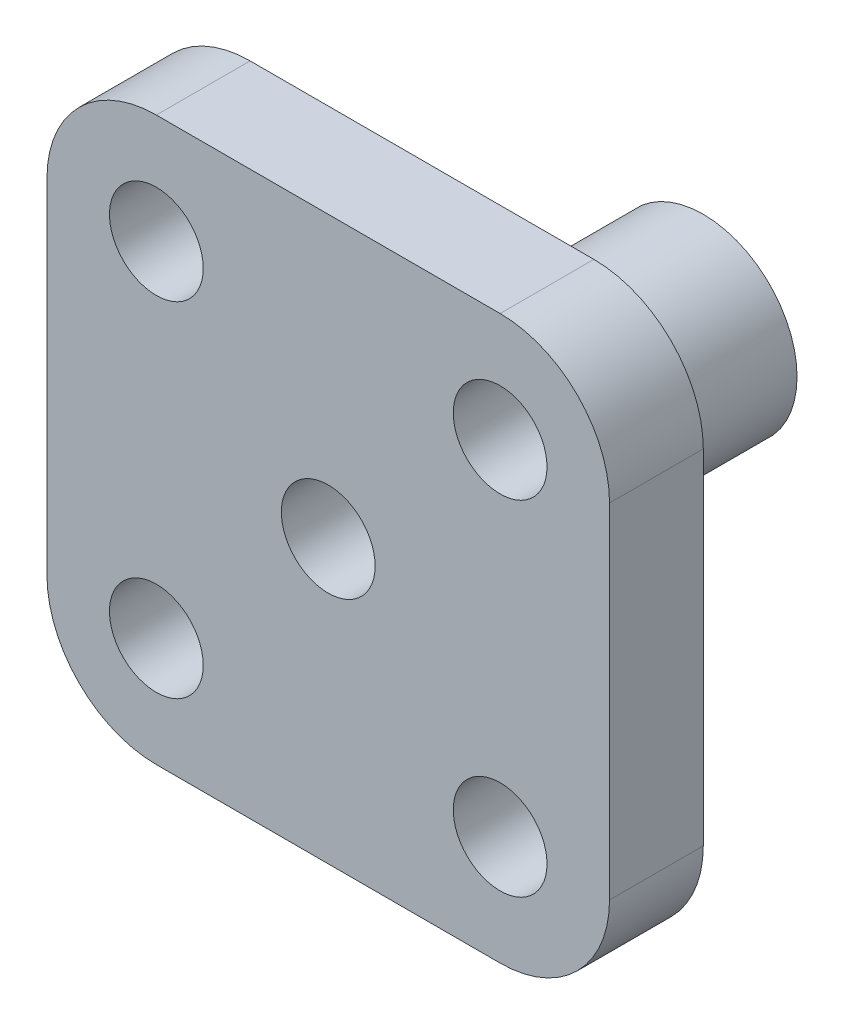
from build123d import *

# Parameters (mm, degrees)
SKETCH1_W           = 0.75
SKETCH1_H           = 2.25
SKETCH2_W           = 4.5
SKETCH2_H           = 4.5
BOSS_EXTRUDE1_DEPTH = 0.75
FILLET2_R           = 0.875
SKETCH6_R           = 0.375
CUT_EXTRUDE1_DEPTH  = 0.75
SKETCH9_R           = 0.65625
CUT_EXTRUDE2_DEPTH  = 2.25


with BuildPart() as part:
    # Sketch1 → Revolve1 (revolve)
    with BuildSketch(Plane(origin=(0, 0, 0), x_dir=(1, 0, 0), z_dir=(0, 1, 0))):
        with Locations((0.375, 1.125)):
            Rectangle(SKETCH1_W, SKETCH1_H)
    revolve(axis=Axis((0, 0, -2.883913043), (0, 0, 1)))

    # Sketch2 → Boss-Extrude1 (add)
    with BuildSketch(Plane.XY):
        Rectangle(SKETCH2_W, SKETCH2_H)
    extrude(amount=BOSS_EXTRUDE1_DEPTH)

    # Fillet2
    fillet2_edges = [part.edges().sort_by_distance(p)[0] for p in [
        (2.25, -2.25, 0.375),
        (2.25, 2.25, 0.375),
        (-2.25, 2.25, 0.375),
        (-2.25, -2.25, 0.375),
    ]]
    fillet(fillet2_edges, radius=FILLET2_R)

    # Sketch6 → Cut-Extrude1 (cut)
    with BuildSketch(Plane.XY.offset(0.75)):
        with Locations((-1.375, 1.375)):
            Circle(SKETCH6_R)
        with Locations((1.375, 1.375)):
            Circle(SKETCH6_R)
        Circle(SKETCH6_R)
        with Locations((-1.375, -1.375)):
            Circle(SKETCH6_R)
        with Locations((1.375, -1.375)):
            Circle(SKETCH6_R)
    extrude(amount=-CUT_EXTRUDE1_DEPTH, mode=Mode.SUBTRACT)

    # Sketch9 → Cut-Extrude2 (cut)
    with BuildSketch(Plane(origin=(0, 0, -2.25), x_dir=(-1, 0, 0), z_dir=(0, 0, -1))):
        Circle(SKETCH9_R)
    extrude(amount=-CUT_EXTRUDE2_DEPTH, mode=Mode.SUBTRACT)


solid = part.part
